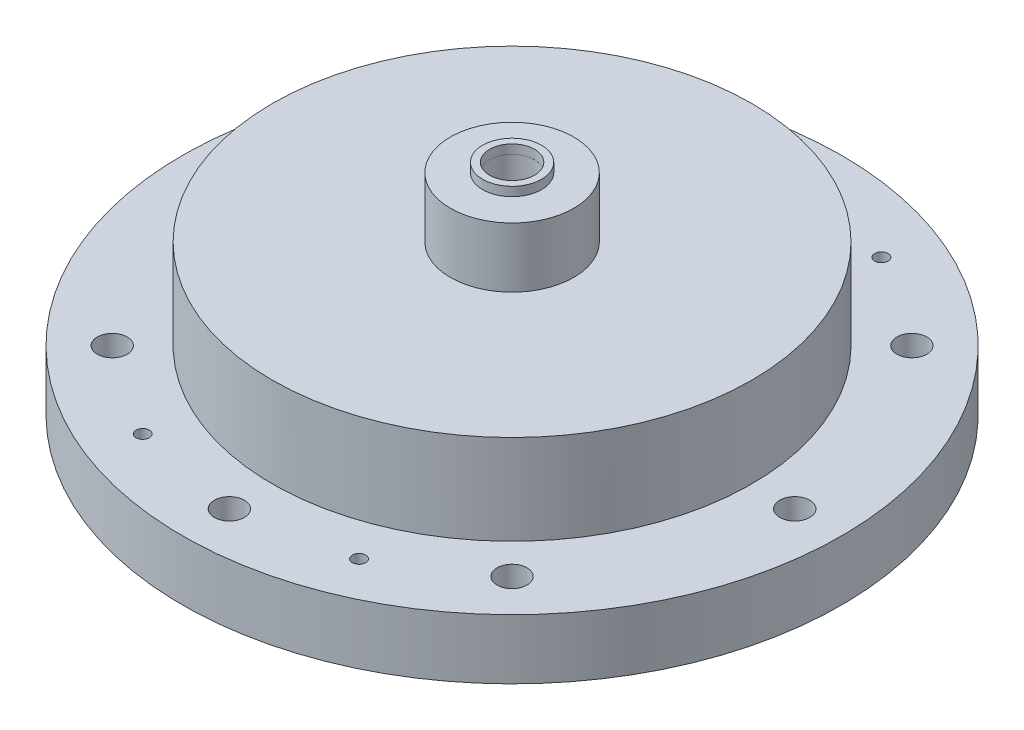
from build123d import *

# Parameters (mm, degrees)
SKETCH1_R           = 50.8
BOSS_EXTRUDE1_DEPTH = 25.4
SKETCH2_R           = 69.85
SKETCH2_R_2         = 50.8
BOSS_EXTRUDE2_DEPTH = 12.7
CUT_EXTRUDE2_REACH  = 27.4
SKETCH4_R           = 3.175
SKETCH5_R           = 12.827
CUT_EXTRUDE3_DEPTH  = 19.05
CUT_EXTRUDE4_REACH  = 8.35
SKETCH6_R           = 1.5875
SKETCH34_R          = 13.081
SKETCH34_R_2        = 4.7625
BOSS_EXTRUDE3_DEPTH = 19.05
SKETCH40_R          = 50.8
BOSS_EXTRUDE5_DEPTH = 6.35
SKETCH38_R          = 6.2484
BOSS_EXTRUDE4_DEPTH = 1.905
SKETCH39_R          = 4.7625
CUT_EXTRUDE7_DEPTH  = 50.8
SKETCH41_R          = 4.7625
CUT_EXTRUDE8_DEPTH  = 6.35
SKETCH46_R          = 3.175
CUT_EXTRUDE10_DEPTH = 6.35
CUT_EXTRUDE11_START = 6.477
SKETCH49_R          = 23.8252
CUT_EXTRUDE11_DEPTH = 3.937
SKETCH50_R          = 1.4097
CUT_EXTRUDE12_DEPTH = 41.005
SKETCH51_R          = 44.45
CUT_EXTRUDE13_DEPTH = 25.4
SKETCH52_R          = 44.45
SKETCH52_R_2        = 4.7625
BOSS_EXTRUDE6_DEPTH = 25.4


with BuildPart() as part:
    # Sketch1 → Boss-Extrude1 (new body)
    with BuildSketch(Plane(origin=(0, 0, 0), x_dir=(1, 0, 0), z_dir=(0, 1, 0))):
        Circle(SKETCH1_R)
    extrude(amount=BOSS_EXTRUDE1_DEPTH)

    # Sketch2 → Boss-Extrude2 (add)
    with BuildSketch(Plane.XZ):
        Circle(SKETCH2_R)
        Circle(SKETCH2_R_2, mode=Mode.SUBTRACT)
    extrude(amount=-BOSS_EXTRUDE2_DEPTH)

    # Sketch4 → Cut-Extrude2 (cut, up to next)
    with BuildSketch(Plane.XZ, mode=Mode.PRIVATE) as cut_extrude2_sk1:
        with Locations((0, -59.9186)):
            Circle(SKETCH4_R)
    cut_extrude2_tool1 = extrude(cut_extrude2_sk1.sketch, amount=-CUT_EXTRUDE2_REACH, mode=Mode.PRIVATE) & part.part
    add(cut_extrude2_tool1.solids().sort_by_distance((0, 0, -59.9186))[0], mode=Mode.SUBTRACT)
    # Sketch4 → Cut-Extrude2 (cut, up to next)
    with BuildSketch(Plane.XZ, mode=Mode.PRIVATE) as cut_extrude2_sk2:
        with Locations((-42.368848379, -42.368848379)):
            Circle(SKETCH4_R)
    cut_extrude2_tool2 = extrude(cut_extrude2_sk2.sketch, amount=-CUT_EXTRUDE2_REACH, mode=Mode.PRIVATE) & part.part
    add(cut_extrude2_tool2.solids().sort_by_distance((-42.368848, 0, -42.368848))[0], mode=Mode.SUBTRACT)
    # Sketch4 → Cut-Extrude2 (cut, up to next)
    with BuildSketch(Plane.XZ, mode=Mode.PRIVATE) as cut_extrude2_sk3:
        with Locations((-59.9186, 0)):
            Circle(SKETCH4_R)
    cut_extrude2_tool3 = extrude(cut_extrude2_sk3.sketch, amount=-CUT_EXTRUDE2_REACH, mode=Mode.PRIVATE) & part.part
    add(cut_extrude2_tool3.solids().sort_by_distance((-59.9186, 0, 0))[0], mode=Mode.SUBTRACT)
    # Sketch4 → Cut-Extrude2 (cut, up to next)
    with BuildSketch(Plane.XZ, mode=Mode.PRIVATE) as cut_extrude2_sk4:
        with Locations((-42.368848379, 42.368848379)):
            Circle(SKETCH4_R)
    cut_extrude2_tool4 = extrude(cut_extrude2_sk4.sketch, amount=-CUT_EXTRUDE2_REACH, mode=Mode.PRIVATE) & part.part
    add(cut_extrude2_tool4.solids().sort_by_distance((-42.368848, 0, 42.368848))[0], mode=Mode.SUBTRACT)
    # Sketch4 → Cut-Extrude2 (cut, up to next)
    with BuildSketch(Plane.XZ, mode=Mode.PRIVATE) as cut_extrude2_sk5:
        with Locations((0, 59.9186)):
            Circle(SKETCH4_R)
    cut_extrude2_tool5 = extrude(cut_extrude2_sk5.sketch, amount=-CUT_EXTRUDE2_REACH, mode=Mode.PRIVATE) & part.part
    add(cut_extrude2_tool5.solids().sort_by_distance((0, 0, 59.9186))[0], mode=Mode.SUBTRACT)
    # Sketch4 → Cut-Extrude2 (cut, up to next)
    with BuildSketch(Plane.XZ, mode=Mode.PRIVATE) as cut_extrude2_sk6:
        with Locations((42.368848379, 42.368848379)):
            Circle(SKETCH4_R)
    cut_extrude2_tool6 = extrude(cut_extrude2_sk6.sketch, amount=-CUT_EXTRUDE2_REACH, mode=Mode.PRIVATE) & part.part
    add(cut_extrude2_tool6.solids().sort_by_distance((42.368848, 0, 42.368848))[0], mode=Mode.SUBTRACT)
    # Sketch4 → Cut-Extrude2 (cut, up to next)
    with BuildSketch(Plane.XZ, mode=Mode.PRIVATE) as cut_extrude2_sk7:
        with Locations((59.9186, 0)):
            Circle(SKETCH4_R)
    cut_extrude2_tool7 = extrude(cut_extrude2_sk7.sketch, amount=-CUT_EXTRUDE2_REACH, mode=Mode.PRIVATE) & part.part
    add(cut_extrude2_tool7.solids().sort_by_distance((59.9186, 0, 0))[0], mode=Mode.SUBTRACT)
    # Sketch4 → Cut-Extrude2 (cut, up to next)
    with BuildSketch(Plane.XZ, mode=Mode.PRIVATE) as cut_extrude2_sk8:
        with Locations((42.368848379, -42.368848379)):
            Circle(SKETCH4_R)
    cut_extrude2_tool8 = extrude(cut_extrude2_sk8.sketch, amount=-CUT_EXTRUDE2_REACH, mode=Mode.PRIVATE) & part.part
    add(cut_extrude2_tool8.solids().sort_by_distance((42.368848, 0, -42.368848))[0], mode=Mode.SUBTRACT)

    # Sketch5 → Cut-Extrude3 (cut)
    with BuildSketch(Plane(origin=(0, 25.4, 0), x_dir=(1, 0, 0), z_dir=(0, 1, 0))):
        Circle(SKETCH5_R)
    extrude(amount=-CUT_EXTRUDE3_DEPTH, mode=Mode.SUBTRACT)

    # Sketch6 → Cut-Extrude4 (cut, up to next)
    with BuildSketch(Plane(origin=(0, 6.35, 0), x_dir=(1, 0, 0), z_dir=(0, 1, 0)), mode=Mode.PRIVATE) as cut_extrude4_sk1:
        Circle(SKETCH6_R)
    cut_extrude4_tool1 = extrude(cut_extrude4_sk1.sketch, amount=-CUT_EXTRUDE4_REACH, mode=Mode.PRIVATE) & part.part
    add(cut_extrude4_tool1.solids().sort_by_distance((0, 6.35, 0))[0], mode=Mode.SUBTRACT)

    # Sketch34 → Boss-Extrude3 (add)
    with BuildSketch(Plane(origin=(0, 25.4, 0), x_dir=(1, 0, 0), z_dir=(0, 1, 0))):
        Circle(SKETCH34_R)
        Circle(SKETCH34_R_2, mode=Mode.SUBTRACT)
    extrude(amount=BOSS_EXTRUDE3_DEPTH)

    # Sketch40 → Boss-Extrude5 (add)
    with BuildSketch(Plane(origin=(0, 25.4, 0), x_dir=(1, 0, 0), z_dir=(0, 1, 0))):
        Circle(SKETCH40_R)
    extrude(amount=BOSS_EXTRUDE5_DEPTH)

    # Sketch41 → Cut-Extrude8 (cut)
    with BuildSketch(Plane(origin=(0, 31.75, 0), x_dir=(1, 0, 0), z_dir=(0, 1, 0))):
        Circle(SKETCH41_R)
    extrude(amount=-CUT_EXTRUDE8_DEPTH, mode=Mode.SUBTRACT)

    # Sketch46 → Cut-Extrude10 (cut)
    with BuildSketch(Plane.XZ):
        with Locations((-22.929855511, 55.357568157)):
            Circle(SKETCH46_R)
        with Locations((22.929855511, 55.357568157)):
            Circle(SKETCH46_R)
        with Locations((-22.929855511, -55.357568157)):
            Circle(SKETCH46_R)
        with Locations((22.929855511, -55.357568157)):
            Circle(SKETCH46_R)
    extrude(amount=-CUT_EXTRUDE10_DEPTH, mode=Mode.SUBTRACT)

    # Sketch49 → Cut-Extrude11 (cut)
    with BuildSketch(Plane.XZ.offset(-6.477).offset(CUT_EXTRUDE11_START)):
        Circle(SKETCH49_R)
    extrude(amount=-CUT_EXTRUDE11_DEPTH, mode=Mode.SUBTRACT)

    # Sketch50 → Cut-Extrude12 (cut, through all)
    with BuildSketch(Plane.XZ.offset(-6.35)):
        with Locations((-22.929855511, 55.357568157)):
            Circle(SKETCH50_R)
        with Locations((22.929855511, 55.357568157)):
            Circle(SKETCH50_R)
        with Locations((-22.929855511, -55.357568157)):
            Circle(SKETCH50_R)
        with Locations((22.929855511, -55.357568157)):
            Circle(SKETCH50_R)
    extrude(amount=-CUT_EXTRUDE12_DEPTH, mode=Mode.SUBTRACT)

    # Sketch51 → Cut-Extrude13 (cut)
    with BuildSketch(Plane.XZ):
        Circle(SKETCH51_R)
    extrude(amount=-CUT_EXTRUDE13_DEPTH, mode=Mode.SUBTRACT)

    # Sketch52 → Boss-Extrude6 (add)
    with BuildSketch(Plane(origin=(0, 0, 0), x_dir=(-1, 0, 0), z_dir=(0, -1, 0))):
        Circle(SKETCH52_R)
        Circle(SKETCH52_R_2, mode=Mode.SUBTRACT)
    extrude(amount=-BOSS_EXTRUDE6_DEPTH)


with BuildPart() as body_2:
    # Sketch38 → Boss-Extrude4 (new body)
    with BuildSketch(Plane(origin=(0, 44.45, 0), x_dir=(1, 0, 0), z_dir=(0, 1, 0))):
        Circle(SKETCH38_R)
    extrude(amount=BOSS_EXTRUDE4_DEPTH)

    # Sketch39 → Cut-Extrude7 (cut)
    with BuildSketch(Plane(origin=(0, 46.355, 0), x_dir=(1, 0, 0), z_dir=(0, 1, 0))):
        Circle(SKETCH39_R)
    extrude(amount=-CUT_EXTRUDE7_DEPTH, mode=Mode.SUBTRACT)


solid = Compound([part.part, body_2.part])
